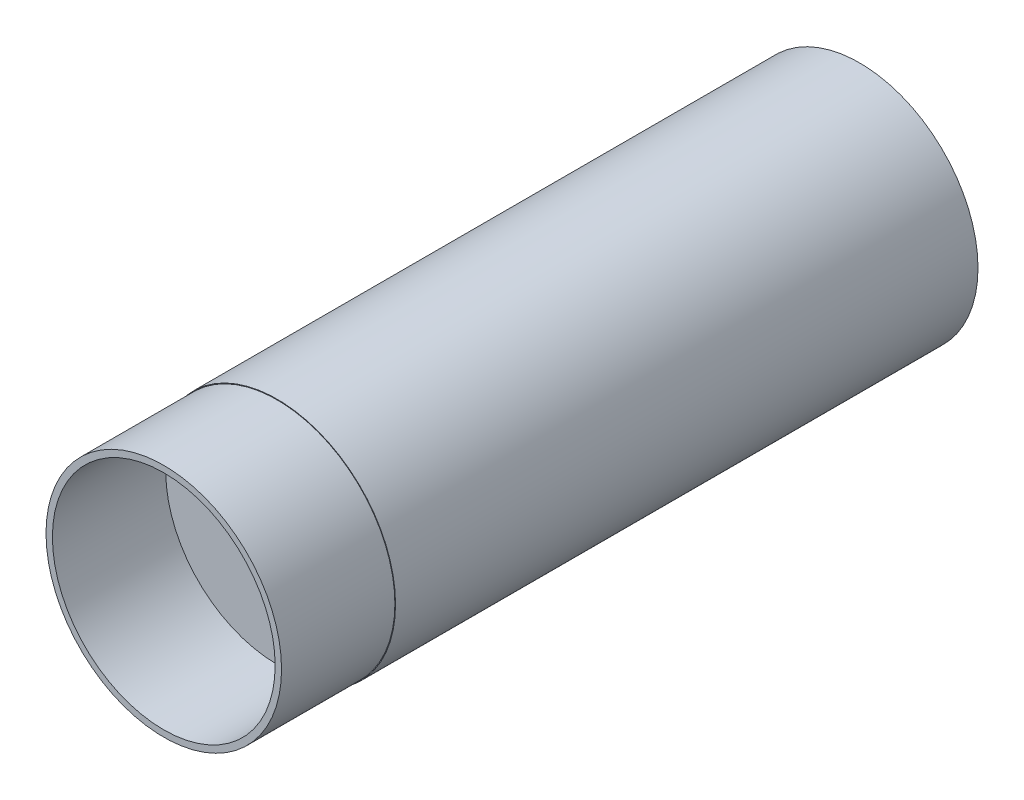
from build123d import *

# Parameters (mm, degrees)
SKETCH1_R           = 18.4
SKETCH1_R_2         = 17.4
BOSS_EXTRUDE1_DEPTH = 17.71
BOSS_EXTRUDE2_START = -91
SKETCH1_2_R         = 18.5
SKETCH1_2_R_2       = 17.4
SKETCH1_2_R_3       = 18.4
BOSS_EXTRUDE2_DEPTH = 91


with BuildPart() as part:
    # Sketch1 → Boss-Extrude1 (new body)
    with BuildSketch(Plane.XY):
        Circle(SKETCH1_R)
        Circle(SKETCH1_R_2, mode=Mode.SUBTRACT)
    extrude(amount=BOSS_EXTRUDE1_DEPTH)

    # Sketch1_2 → Boss-Extrude2 (add)
    # profile 1 of 3: a face of its own
    with BuildSketch(Plane.XY.offset(BOSS_EXTRUDE2_START)):
        Circle(SKETCH1_2_R)
        Circle(SKETCH1_2_R_2, mode=Mode.SUBTRACT)
    # profile 2 of 3: a face of its own
    with BuildSketch(Plane.XY.offset(BOSS_EXTRUDE2_START)):
        Circle(SKETCH1_2_R)
        Circle(SKETCH1_2_R_3, mode=Mode.SUBTRACT)
    # profile 3 of 3: a face of its own
    with BuildSketch(Plane.XY.offset(BOSS_EXTRUDE2_START)):
        Circle(SKETCH1_2_R_2)
    extrude(amount=BOSS_EXTRUDE2_DEPTH)


solid = part.part
